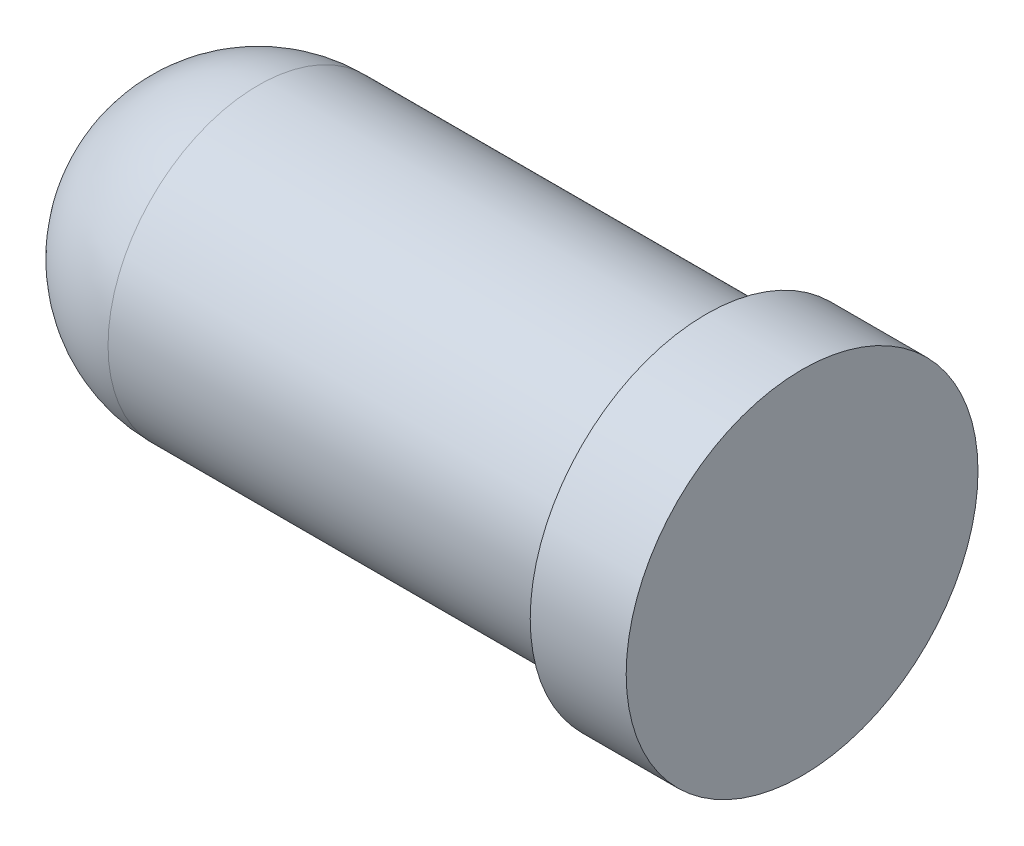
from build123d import *

# Parameters (mm, degrees)
SKETCH1_R           = 2.35
BOSS_EXTRUDE1_DEPTH = 7
SKETCH2_R           = 2.75
BOSS_EXTRUDE2_DEPTH = 1.5


with BuildPart() as part:
    # Sketch1 → Boss-Extrude1 (new body)
    with BuildSketch(Plane(origin=(0, 0, 0), x_dir=(0, 0, -1), z_dir=(1, 0, 0))):
        Circle(SKETCH1_R)
    extrude(amount=BOSS_EXTRUDE1_DEPTH)

    # Sketch2 → Boss-Extrude2 (add)
    with BuildSketch(Plane(origin=(7, 0, 0), x_dir=(0, 0, -1), z_dir=(1, 0, 0))):
        Circle(SKETCH2_R)
    extrude(amount=BOSS_EXTRUDE2_DEPTH)

    # Sketch15 → Revolve1 (revolve)
    with BuildSketch(Plane.XY):
        with BuildLine():
            Line((0, 2.35), (0, -2.35))
            ThreePointArc((0, -2.35), (-2.35, 0), (0, 2.35))
        make_face()
    revolve(axis=Axis((0, 2.35, 0), (0, -1, 0)))


solid = part.part
